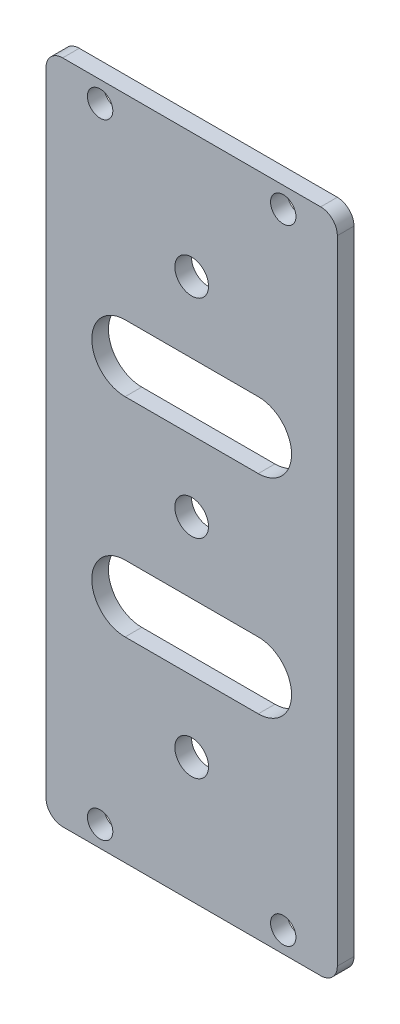
from build123d import *

# Parameters (mm, degrees)
SKETCH_1_W               = 35
SKETCH_1_H               = 80
EXTRUDE_1_DEPTH          = 2
SKETCH_2_R               = 1.525
CUT_EXTRUDE_1_DEPTH      = 2
FILLET_1_R               = 2
SKETCH_3_R               = 2.025
CUT_EXTRUDE_2_DEPTH      = 10
CUT_EXTRUDE_3_DEPTH      = 1
CUT_EXTRUDE_3_DEPTH_BACK = 3


with BuildPart() as part:
    # 草图1 → 凸台-拉伸1 (new body)
    with BuildSketch(Plane.XY):
        Rectangle(SKETCH_1_W, SKETCH_1_H)
    extrude(amount=EXTRUDE_1_DEPTH)

    # 草图2 → 切除-拉伸1 (cut)
    with BuildSketch(Plane.XY.offset(2)):
        with Locations((11, 37.5)):
            Circle(SKETCH_2_R)
        with Locations((-11, 37.5)):
            Circle(SKETCH_2_R)
        with Locations((-11, -37.5)):
            Circle(SKETCH_2_R)
        with Locations((11, -37.5)):
            Circle(SKETCH_2_R)
    extrude(amount=-CUT_EXTRUDE_1_DEPTH, mode=Mode.SUBTRACT)

    # 圆角1
    fillet_1_edges = [part.edges().sort_by_distance(p)[0] for p in [
        (17.5, -40, 1),
        (-17.5, -40, 1),
        (-17.5, 40, 1),
        (17.5, 40, 1),
    ]]
    fillet(fillet_1_edges, radius=FILLET_1_R)

    # 草图3 → 切除-拉伸2 (cut)
    with BuildSketch(Plane.XY.offset(2)):
        with Locations((0, 25)):
            Circle(SKETCH_3_R)
        Circle(SKETCH_3_R)
        with Locations((0, -25)):
            Circle(SKETCH_3_R)
    extrude(amount=-CUT_EXTRUDE_2_DEPTH, mode=Mode.SUBTRACT)

    # 草图4 → 切除-拉伸3 (cut, two sides)
    with BuildSketch(Plane.XY.offset(2)) as cut_extrude_3_sk:
        with BuildLine():
            Line((-8, 16.5), (8, 16.5))
            ThreePointArc((8, 16.5), (12, 12.5), (8, 8.5))
            Line((8, 8.5), (-8, 8.5))
            ThreePointArc((-8, 8.5), (-12, 12.5), (-8, 16.5))
        make_face()
        with BuildLine():
            Line((-8, -16.5), (8, -16.5))
            ThreePointArc((8, -16.5), (12, -12.5), (8, -8.5))
            Line((8, -8.5), (-8, -8.5))
            ThreePointArc((-8, -8.5), (-12, -12.5), (-8, -16.5))
        make_face()
    extrude(amount=CUT_EXTRUDE_3_DEPTH, mode=Mode.SUBTRACT)
    extrude(cut_extrude_3_sk.sketch, amount=-CUT_EXTRUDE_3_DEPTH_BACK, mode=Mode.SUBTRACT)


solid = part.part
